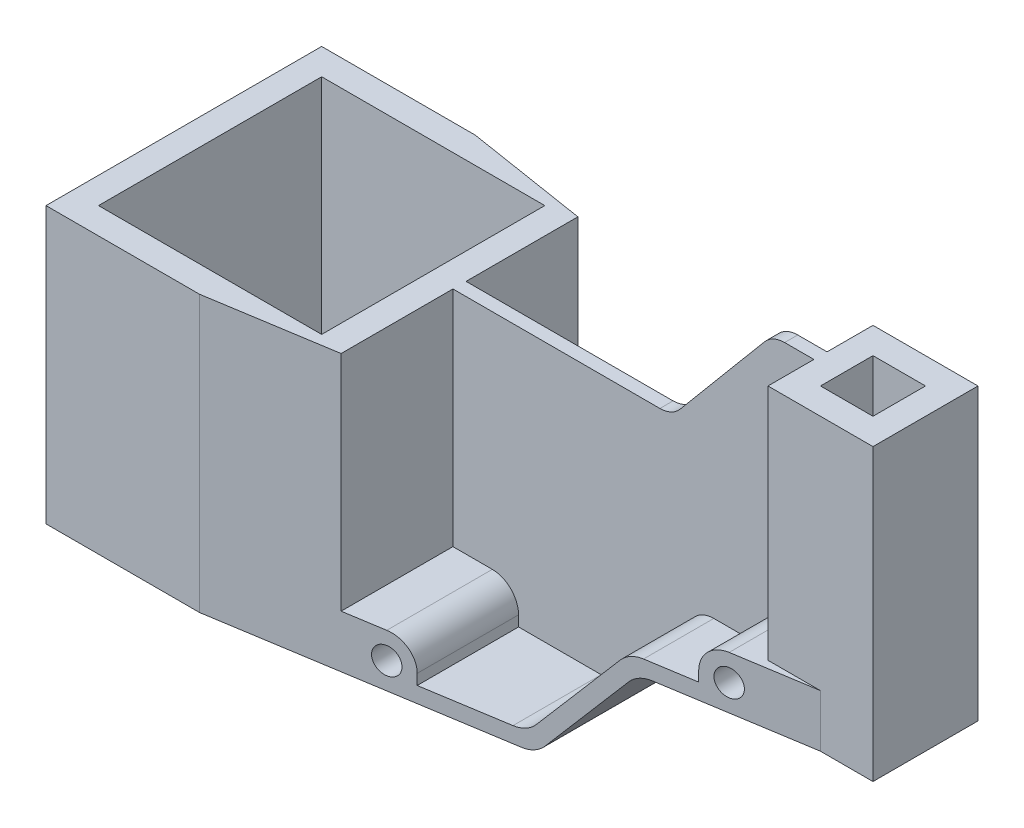
from build123d import *

# Parameters (mm, degrees)
SKETCH1_W           = 282.5
SKETCH1_H           = 150.5
BOSS_EXTRUDE2_DEPTH = 105
SKETCH16_W          = 80
SKETCH16_H          = 40
SKETCH16_W_2        = 130
SKETCH16_H_2        = 45.5
CUT_EXTRUDE10_DEPTH = 105
SKETCH17_W          = 20
SKETCH17_H          = 32.5
CUT_EXTRUDE11_DEPTH = 110.5
CUT_EXTRUDE12_DEPTH = 90.5
SKETCH19_W          = 92.5
SKETCH19_H          = 50
CUT_EXTRUDE13_DEPTH = 14
SKETCH20_W          = 92.5
SKETCH20_H          = 50
CUT_EXTRUDE14_DEPTH = 14
SKETCH21_W          = 25
SKETCH21_H          = 50
CUT_EXTRUDE15_DEPTH = 85
SKETCH22_W          = 85
SKETCH22_H          = 85
CUT_EXTRUDE16_DEPTH = 105
CUT_EXTRUDE17_DEPTH = 50
CUT_EXTRUDE18_DEPTH = 120
CUT_EXTRUDE19_DEPTH = 50
SKETCH27_R          = 5
CUT_EXTRUDE20_DEPTH = 120
CUT_EXTRUDE21_DEPTH = 160
FILLET1_R           = 10
FILLET2_R           = 10
CUT_EXTRUDE22_DEPTH = 160
FILLET3_R           = 10
SKETCH30_W          = 20
SKETCH30_H          = 20
CUT_EXTRUDE23_DEPTH = 160


with BuildPart() as part:
    # Sketch1 → Boss-Extrude2 (new body)
    with BuildSketch(Plane.XY):
        with Locations((93.419387358, 47.520353684)):
            Rectangle(SKETCH1_W, SKETCH1_H)
    extrude(amount=BOSS_EXTRUDE2_DEPTH)

    # Sketch16 → Cut-Extrude10 (cut)
    with BuildSketch(Plane.XY.offset(105)):
        with Locations((194.669387358, -7.729646316)):
            Rectangle(SKETCH16_W, SKETCH16_H)
        with Locations((17.169387358, 100.020353684)):
            Rectangle(SKETCH16_W_2, SKETCH16_H_2)
    extrude(amount=-CUT_EXTRUDE10_DEPTH, mode=Mode.SUBTRACT)

    # Sketch17 → Cut-Extrude11 (cut)
    with BuildSketch(Plane(origin=(0, 122.770353684, 0), x_dir=(1, 0, 0), z_dir=(0, 1, 0))):
        with Locations((224.669387358, -16.25)):
            Rectangle(SKETCH17_W, SKETCH17_H)
        with Locations((224.669387358, -88.75)):
            Rectangle(SKETCH17_W, SKETCH17_H)
    extrude(amount=-CUT_EXTRUDE11_DEPTH, mode=Mode.SUBTRACT)

    # Sketch18 → Cut-Extrude12 (cut)
    with BuildSketch(Plane(origin=(0, 122.770353684, 0), x_dir=(1, 0, 0), z_dir=(0, 1, 0))):
        Polygon((214.669387358, -32.5), (194.669387358, -32.5), (194.669387358, -50), (82.169387358, -50), (82.169387358, 0), (214.669387358, 0), align=None)
        Polygon((214.669387358, -72.5), (194.669387358, -72.5), (194.669387358, -55), (82.169387358, -55), (82.169387358, -105), (214.669387358, -105), align=None)
    extrude(amount=-CUT_EXTRUDE12_DEPTH, mode=Mode.SUBTRACT)

    # Sketch19 → Cut-Extrude13 (cut)
    with BuildSketch(Plane(origin=(0, 32.270353684, 0), x_dir=(1, 0, 0), z_dir=(0, 1, 0))):
        with Locations((128.419387358, -80)):
            Rectangle(SKETCH19_W, SKETCH19_H)
    extrude(amount=-CUT_EXTRUDE13_DEPTH, mode=Mode.SUBTRACT)

    # Sketch20 → Cut-Extrude14 (cut)
    with BuildSketch(Plane(origin=(0, 32.270353684, 0), x_dir=(1, 0, 0), z_dir=(0, 1, 0))):
        with Locations((128.419387358, -25)):
            Rectangle(SKETCH20_W, SKETCH20_H)
    extrude(amount=-CUT_EXTRUDE14_DEPTH, mode=Mode.SUBTRACT)

    # Sketch21 → Cut-Extrude15 (cut)
    with BuildSketch(Plane(origin=(0, 77.270353684, 0), x_dir=(1, 0, 0), z_dir=(0, 1, 0))):
        with Locations((69.669387358, -25)):
            Rectangle(SKETCH21_W, SKETCH21_H)
        with Locations((69.669387358, -80)):
            Rectangle(SKETCH21_W, SKETCH21_H)
    extrude(amount=-CUT_EXTRUDE15_DEPTH, mode=Mode.SUBTRACT)

    # Sketch22 → Cut-Extrude16 (cut)
    with BuildSketch(Plane(origin=(0, 77.270353684, 0), x_dir=(1, 0, 0), z_dir=(0, 1, 0))):
        with Locations((4.669387358, -52.5)):
            Rectangle(SKETCH22_W, SKETCH22_H)
    extrude(amount=-CUT_EXTRUDE16_DEPTH, mode=Mode.SUBTRACT)

    # Sketch24 → Cut-Extrude17 (cut)
    with BuildSketch(Plane.XY.offset(105)):
        Polygon((151.871541409, 18.270353684), (118.307556162, -21.729646316), (82.169387358, -21.729646316), (82.169387358, -7.729646316), (82.169387358, 18.270353684), align=None)
    extrude(amount=-CUT_EXTRUDE17_DEPTH, mode=Mode.SUBTRACT)

    # Sketch25 → Cut-Extrude18 (cut)
    with BuildSketch(Plane.XY.offset(105)):
        Polygon((154.669387358, -27.729646316), (154.669387358, 12.270353684), (121.105402111, -27.729646316), align=None)
    extrude(amount=-CUT_EXTRUDE18_DEPTH, mode=Mode.SUBTRACT)

    # Sketch26 → Cut-Extrude19 (cut)
    with BuildSketch(Plane(origin=(0, 0, 0), x_dir=(-1, 0, 0), z_dir=(0, 0, -1))):
        Polygon((-82.169387358, -7.729646316), (-82.169387358, -21.729646316), (-118.307556162, -21.729646316), (-151.871541409, 18.270353684), (-82.169387358, 18.270353684), align=None)
    extrude(amount=-CUT_EXTRUDE19_DEPTH, mode=Mode.SUBTRACT)

    # Sketch27 → Cut-Extrude20 (cut)
    with BuildSketch(Plane(origin=(0, 0, 0), x_dir=(-1, 0, 0), z_dir=(0, 0, -1))):
        with Locations((-184.669387358, 22.270353684)):
            Circle(SKETCH27_R)
        with Locations((-72.169387358, -17.729646316)):
            Circle(SKETCH27_R)
    extrude(amount=-CUT_EXTRUDE20_DEPTH, mode=Mode.SUBTRACT)

    # Sketch28 → Cut-Extrude21 (cut)
    with BuildSketch(Plane.XZ.offset(27.729646316)):
        Polygon((10.669387358, 105), (214.669387358, 105), (214.669387358, 72.5), align=None)
        Polygon((214.669387358, 32.5), (10.669387358, 0), (214.669387358, 0), align=None)
    extrude(amount=-CUT_EXTRUDE21_DEPTH, mode=Mode.SUBTRACT)

    # Fillet1
    fillet1_edges = [part.edges().sort_by_distance(p)[0] for p in [
        (174.669387358, 32.270353684, 38.06372549),
        (82.169387358, -7.729646316, 30.695465686),
        (82.169387358, -7.729646316, 74.304534314),
        (174.669387358, 32.270353684, 66.93627451),
    ]]
    fillet(fillet1_edges, radius=FILLET1_R)

    # Fillet2
    fillet2_edges = [part.edges().sort_by_distance(p)[0] for p in [
        (151.871541409, 18.270353684, 68.752279395),
        (118.307556162, -21.729646316, 71.425881161),
        (151.871541409, 18.270353684, 36.247720605),
        (118.307556162, -21.729646316, 33.574118839),
        (154.669387358, 12.270353684, 52.5),
        (121.105402111, -27.729646316, 52.5),
    ]]
    fillet(fillet2_edges, radius=FILLET2_R)

    # Sketch29 → Cut-Extrude22 (cut)
    with BuildSketch(Plane.XY.offset(55)):
        Polygon((82.169387358, 77.270353684), (140.676980695, 77.270353684), (178.856013913, 122.770353684), (82.169387358, 122.770353684), align=None)
    extrude(amount=-CUT_EXTRUDE22_DEPTH, mode=Mode.SUBTRACT)

    # Fillet3
    fillet3_edges = [part.edges().sort_by_distance(p)[0] for p in [
        (178.856013913, 122.770353684, 52.5),
        (140.676980695, 77.270353684, 52.5),
    ]]
    fillet(fillet3_edges, radius=FILLET3_R)

    # Sketch30 → Cut-Extrude23 (cut)
    with BuildSketch(Plane(origin=(0, 122.770353684, 0), x_dir=(1, 0, 0), z_dir=(0, 1, 0))):
        with Locations((214.669387358, -52.5)):
            Rectangle(SKETCH30_W, SKETCH30_H)
    extrude(amount=-CUT_EXTRUDE23_DEPTH, mode=Mode.SUBTRACT)


solid = part.part
